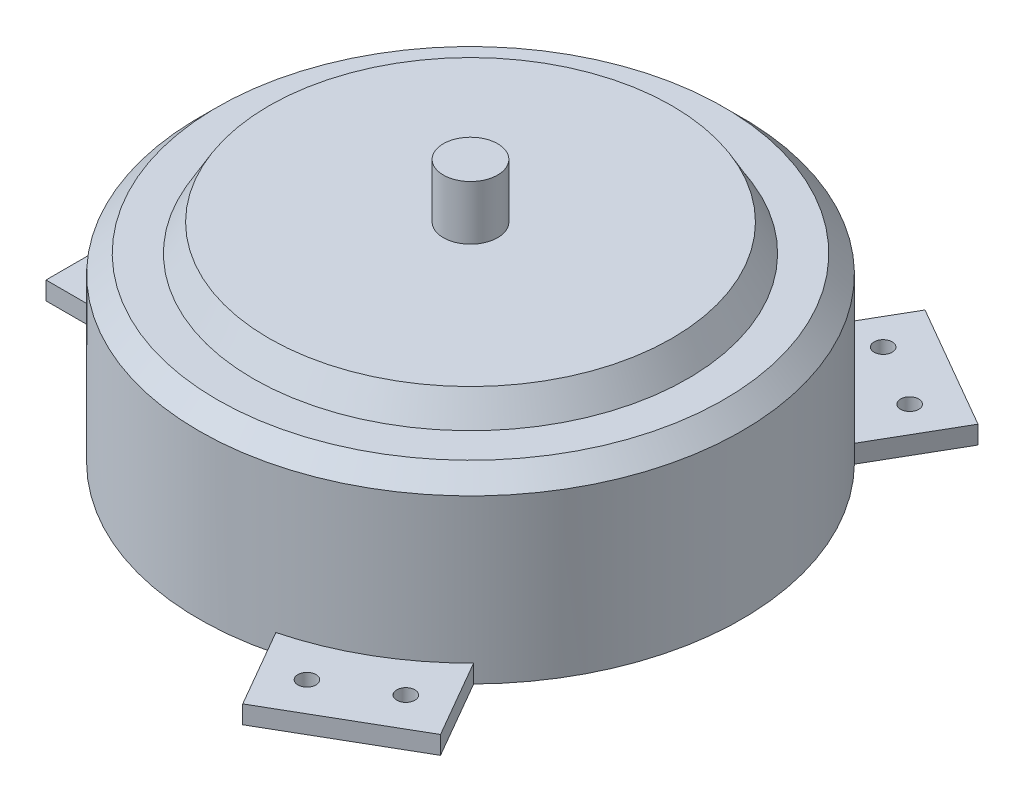
from build123d import *

# Parameters (mm, degrees)
SKETCH1_R           = 150
BOSS_EXTRUDE1_DEPTH = 100
CHAMFER1_SIZE       = 10
BOSS_EXTRUDE2_START = -100
BOSS_EXTRUDE2_DEPTH = 10
SKETCH3_R           = 5
CUT_EXTRUDE1_DEPTH  = 10
CIRPATTERN2_COUNT   = 3
SKETCH4_R           = 120
BOSS_EXTRUDE4_DEPTH = 15
BOSS_EXTRUDE4_TAPER = 30
SKETCH5_R           = 15
BOSS_EXTRUDE5_DEPTH = 30


with BuildPart() as part:
    # Sketch1 → Boss-Extrude1 (new body)
    with BuildSketch(Plane(origin=(0, 0, 0), x_dir=(1, 0, 0), z_dir=(0, 1, 0))):
        Circle(SKETCH1_R)
    extrude(amount=BOSS_EXTRUDE1_DEPTH)

    # Chamfer1
    chamfer1_edges = [part.edges().sort_by_distance(p)[0] for p in [
        (-150, 100, 0),
    ]]
    chamfer(chamfer1_edges, length=CHAMFER1_SIZE)

    # Sketch2 → Boss-Extrude2 (add)
    with BuildSketch(Plane(origin=(0, 100, 0), x_dir=(1, 0, 0), z_dir=(0, 1, 0)).offset(BOSS_EXTRUDE2_START)):
        with BuildLine():
            Line((-194.568322948, -40), (-194.568322948, 40))
            Line((-194.568322948, 40), (-144.568322948, 40))
            ThreePointArc((-144.568322948, 40), (-150, 0), (-144.568322948, -40))
            Line((-144.568322948, -40), (-194.568322948, -40))
        make_face()
    boss_extrude2 = extrude(amount=BOSS_EXTRUDE2_DEPTH)

    # Sketch3 → Cut-Extrude1 (cut)
    with BuildSketch(Plane(origin=(0, 10, 0), x_dir=(1, 0, 0), z_dir=(0, 1, 0))):
        with Locations((-172.284161474, -20)):
            Circle(SKETCH3_R)
        with Locations((-172.284161474, 20)):
            Circle(SKETCH3_R)
    cut_extrude1 = extrude(amount=-CUT_EXTRUDE1_DEPTH, mode=Mode.SUBTRACT)

    # CirPattern2: Boss-Extrude2, Cut-Extrude1 ×3 about axis
    cirpattern2_axis = Axis((0, 0, 0), (0, 1, 0))
    for i in range(1, CIRPATTERN2_COUNT):
        add(boss_extrude2.rotate(cirpattern2_axis, i * 360 / CIRPATTERN2_COUNT))
        add(cut_extrude1.rotate(cirpattern2_axis, i * 360 / CIRPATTERN2_COUNT), mode=Mode.SUBTRACT)

    # Sketch4 → Boss-Extrude4 (add)
    with BuildSketch(Plane(origin=(0, 100, 0), x_dir=(1, 0, 0), z_dir=(0, 1, 0))):
        Circle(SKETCH4_R)
    extrude(amount=BOSS_EXTRUDE4_DEPTH, taper=BOSS_EXTRUDE4_TAPER)

    # Sketch5 → Boss-Extrude5 (add)
    with BuildSketch(Plane(origin=(0, 115, 0), x_dir=(1, 0, 0), z_dir=(0, 1, 0))):
        Circle(SKETCH5_R)
    extrude(amount=BOSS_EXTRUDE5_DEPTH)


solid = part.part
